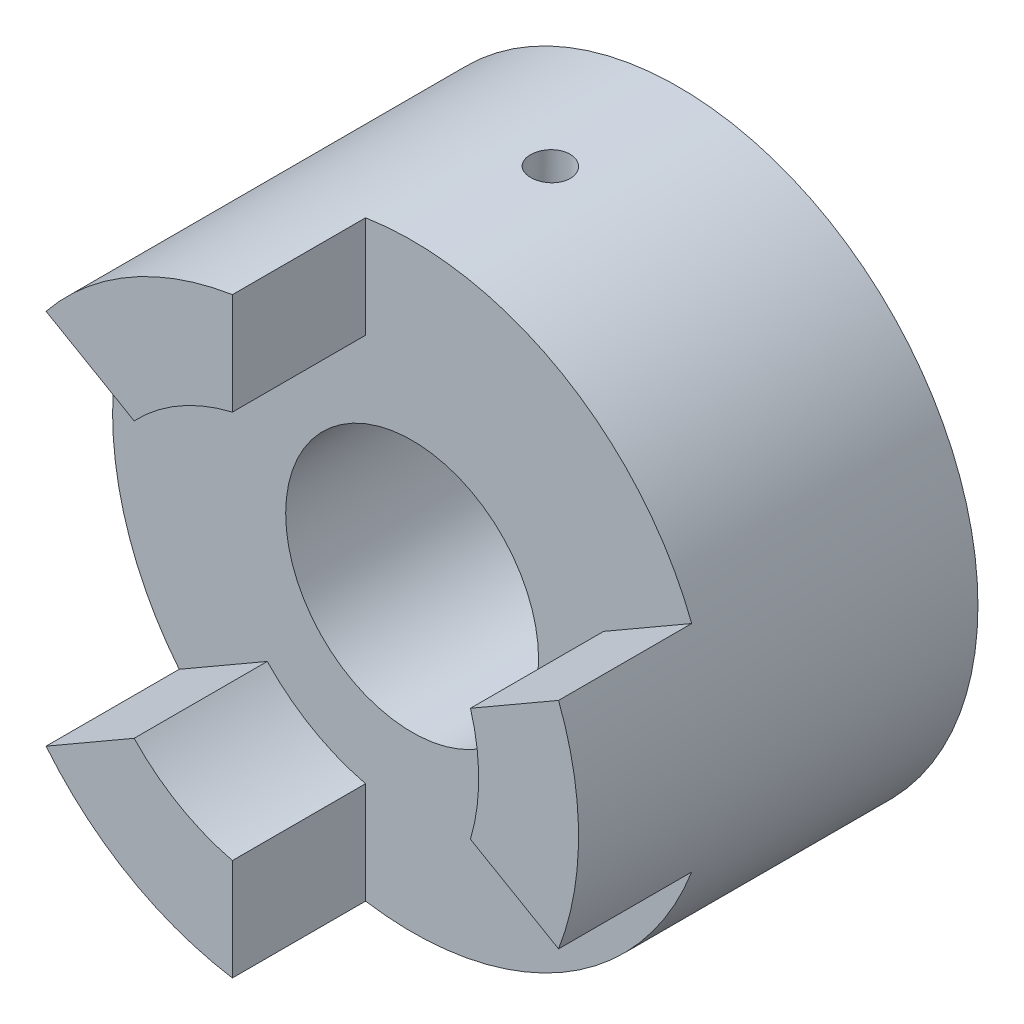
from build123d import *

# Parameters (mm, degrees)
SKETCH1_R                 = 22.5
BOSS_EXTRUDE1_DEPTH       = 20
CUT_EXTRUDE1_REACH        = 22
SKETCH3_R                 = 9.5
F_3_0MM_DOWEL_HOLE1_D     = 3
F_3_0MM_DOWEL_HOLE1_DEPTH = 22
F_3_0MM_DOWEL_HOLE1_TIP   = 0.901291
BOSS_EXTRUDE3_DEPTH       = 10


with BuildPart() as part:
    # Sketch1 → Boss-Extrude1 (new body)
    with BuildSketch(Plane.XY):
        Circle(SKETCH1_R)
    extrude(amount=BOSS_EXTRUDE1_DEPTH)

    # Sketch3 → Cut-Extrude1 (cut, up to next)
    with BuildSketch(Plane.XY.offset(20), mode=Mode.PRIVATE) as cut_extrude1_sk1:
        Circle(SKETCH3_R)
    cut_extrude1_tool1 = extrude(cut_extrude1_sk1.sketch, amount=-CUT_EXTRUDE1_REACH, mode=Mode.PRIVATE) & part.part
    add(cut_extrude1_tool1.solids().sort_by_distance((0, 0, 20))[0], mode=Mode.SUBTRACT)

    # Ø3.0mm Dowel Hole1
    with Locations(Plane(origin=(0.332625, 22.497541, 9.950984), x_dir=(0.999891, -0.014783, 0), z_dir=(0.014783, 0.999891, 0))):
        with Locations((0, 0)):
            Hole(F_3_0MM_DOWEL_HOLE1_D / 2, depth=F_3_0MM_DOWEL_HOLE1_DEPTH)
            with Locations((0, 0, -(F_3_0MM_DOWEL_HOLE1_DEPTH + F_3_0MM_DOWEL_HOLE1_TIP / 2))):  # 118° drill point
                Cone(0, F_3_0MM_DOWEL_HOLE1_D / 2, F_3_0MM_DOWEL_HOLE1_TIP, mode=Mode.SUBTRACT)

    # Sketch6 → Boss-Extrude3 (add)
    with BuildSketch(Plane.XY.offset(20)):
        with BuildLine():
            Line((-17.498377, 14.144144), (-10.881805, 10.324065))
            ThreePointArc((-10.881805, 10.324065), (-7.5, 12.990381), (-3.5, 14.585952))
            Line((-3.5, 14.585952), (-3.5, 22.226111))
            ThreePointArc((-3.5, 22.226111), (-11.25, 19.485572), (-17.498377, 14.144144))
        make_face()
        with BuildLine():
            Line((14.381805, 4.261887), (20.998377, 8.081966))
            ThreePointArc((20.998377, 8.081966), (22.5, 0), (20.998377, -8.081966))
            Line((20.998377, -8.081966), (14.381805, -4.261887))
            ThreePointArc((14.381805, -4.261887), (15, 0), (14.381805, 4.261887))
        make_face()
        with BuildLine():
            Line((-3.5, -14.585952), (-3.5, -22.226111))
            ThreePointArc((-3.5, -22.226111), (-11.25, -19.485572), (-17.498377, -14.144144))
            Line((-17.498377, -14.144144), (-10.881805, -10.324065))
            ThreePointArc((-10.881805, -10.324065), (-7.5, -12.990381), (-3.5, -14.585952))
        make_face()
    extrude(amount=BOSS_EXTRUDE3_DEPTH)


solid = part.part
